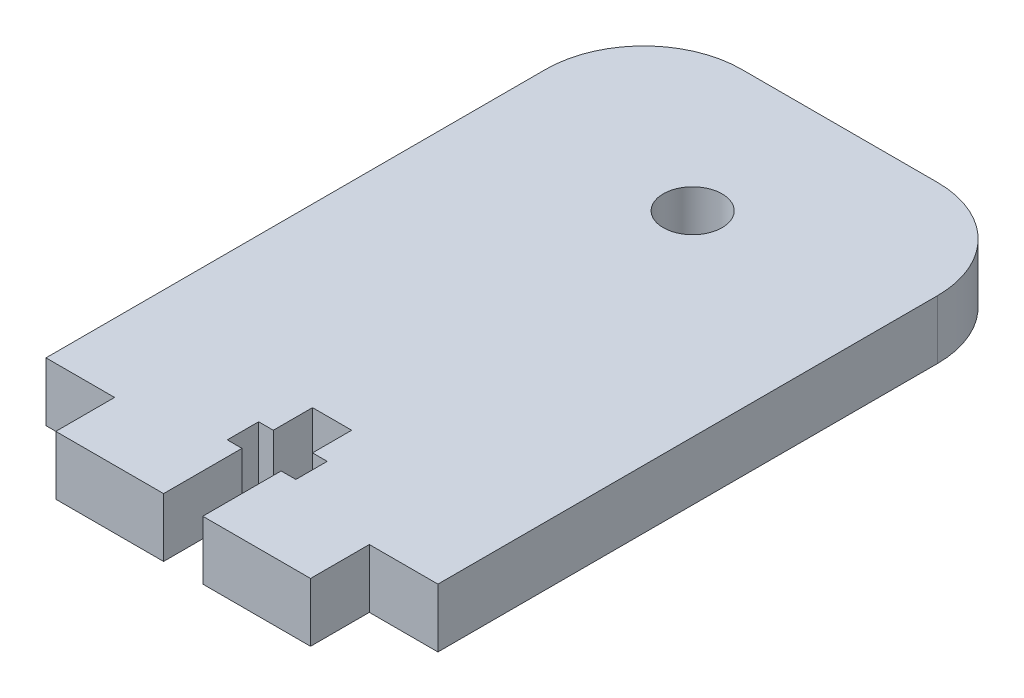
from build123d import *

# Parameters (mm, degrees)
SKETCH1_R           = 3
BOSS_EXTRUDE1_DEPTH = 6


with BuildPart() as part:
    # Sketch1 → Boss-Extrude1 (new body)
    with BuildSketch(Plane(origin=(0, 0, 0), x_dir=(1, 0, 0), z_dir=(0, 1, 0))):
        with BuildLine():
            Line((-9.761766306, 34.452934774), (10.238233694, 34.452934774))
            ThreePointArc((10.238233694, 34.452934774), (17.309301505, 31.524002586), (20.238233694, 24.452934774))
            Line((20.238233694, 24.452934774), (20.238233694, -26.547065226))
            Line((20.238233694, -26.547065226), (13.238233694, -26.547065226))
            Line((13.238233694, -26.547065226), (13.238233694, -32.547065226))
            Line((13.238233694, -32.547065226), (2.238233694, -32.547065226))
            Line((2.238233694, -32.547065226), (2.238233694, -24.547065226))
            Line((2.238233694, -24.547065226), (3.738233694, -24.547065226))
            Line((3.738233694, -24.547065226), (3.738233694, -21.347065226))
            Line((3.738233694, -21.347065226), (2.238233694, -21.347065226))
            Line((2.238233694, -21.347065226), (2.238233694, -17.347065226))
            Line((2.238233694, -17.347065226), (-1.761766306, -17.347065226))
            Line((-1.761766306, -17.347065226), (-1.761766306, -21.347065226))
            Line((-1.761766306, -21.347065226), (-3.261766306, -21.347065226))
            Line((-3.261766306, -21.347065226), (-3.261766306, -24.547065226))
            Line((-3.261766306, -24.547065226), (-1.761766306, -24.547065226))
            Line((-1.761766306, -24.547065226), (-1.761766306, -32.547065226))
            Line((-1.761766306, -32.547065226), (-12.761766306, -32.547065226))
            Line((-12.761766306, -32.547065226), (-12.761766306, -26.547065226))
            Line((-12.761766306, -26.547065226), (-19.761766306, -26.547065226))
            Line((-19.761766306, -26.547065226), (-19.761766306, 24.452934774))
            ThreePointArc((-19.761766306, 24.452934774), (-16.832834118, 31.524002586), (-9.761766306, 34.452934774))
        make_face()
        with Locations((0.238233694, 19.452934774)):
            Circle(SKETCH1_R, mode=Mode.SUBTRACT)
    extrude(amount=BOSS_EXTRUDE1_DEPTH)


solid = part.part
